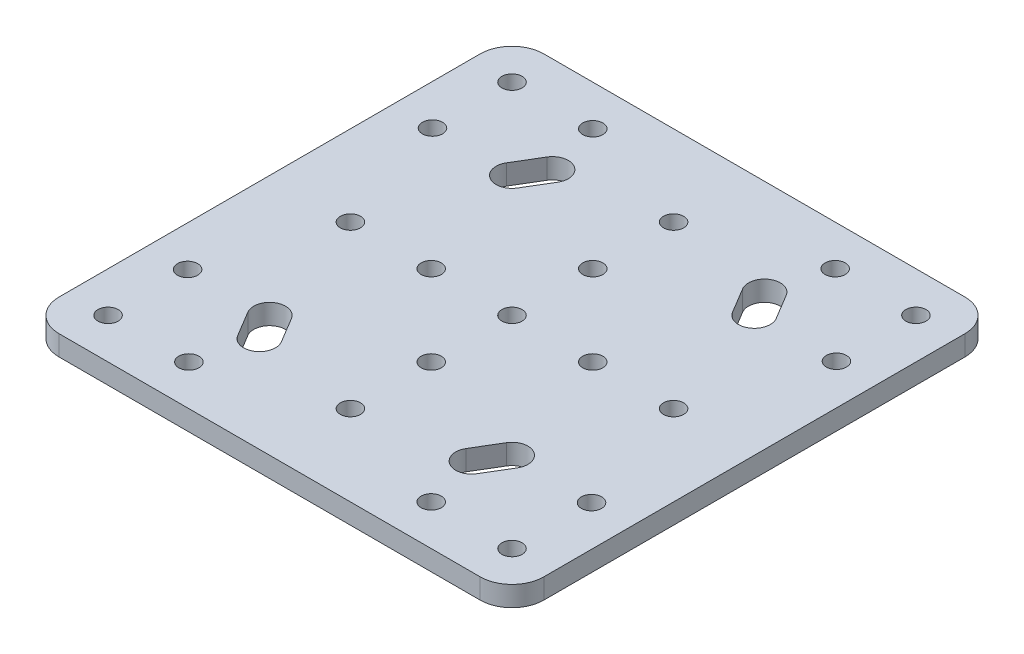
from build123d import *

# Parameters (mm, degrees)
SKETCH1_W           = 101.6
SKETCH1_H           = 114.3
BOSS_EXTRUDE2_DEPTH = 6.35
SKETCH4_W           = 152.4
SKETCH4_H           = 152.4
SKETCH4_W_2         = 101.6
SKETCH4_H_2         = 114.3
BOSS_EXTRUDE4_DEPTH = 6.35
FILLET1_R           = 10
SKETCH5_R           = 3.175
CUT_EXTRUDE1_DEPTH  = 6.35


with BuildPart() as part:
    # Sketch1 → Boss-Extrude2 (new body)
    with BuildSketch(Plane(origin=(0, 0, 0), x_dir=(1, 0, 0), z_dir=(0, 1, 0))):
        Rectangle(SKETCH1_W, SKETCH1_H)
        with BuildLine():
            ThreePointArc((33.812535371, 35.527521223), (40.672478777, 33.812535371), (42.387464629, 40.672478777))
            Line((42.387464629, 40.672478777), (37.624964629, 48.609978777))
            ThreePointArc((37.624964629, 48.609978777), (30.765021223, 50.324964629), (29.050035371, 43.465021223))
            Line((29.050035371, 43.465021223), (33.812535371, 35.527521223))
        make_face(mode=Mode.SUBTRACT)
        with BuildLine():
            ThreePointArc((-33.812535371, -35.527521223), (-40.672478777, -33.812535371), (-42.387464629, -40.672478777))
            Line((-42.387464629, -40.672478777), (-37.624964629, -48.609978777))
            ThreePointArc((-37.624964629, -48.609978777), (-30.765021223, -50.324964629), (-29.050035371, -43.465021223))
            Line((-29.050035371, -43.465021223), (-33.812535371, -35.527521223))
        make_face(mode=Mode.SUBTRACT)
        with BuildLine():
            ThreePointArc((-33.812535371, 35.527521223), (-40.672478777, 33.812535371), (-42.387464629, 40.672478777))
            Line((-42.387464629, 40.672478777), (-37.624964629, 48.609978777))
            ThreePointArc((-37.624964629, 48.609978777), (-30.765021223, 50.324964629), (-29.050035371, 43.465021223))
            Line((-29.050035371, 43.465021223), (-33.812535371, 35.527521223))
        make_face(mode=Mode.SUBTRACT)
        with BuildLine():
            Line((29.050035371, -43.465021223), (33.812535371, -35.527521223))
            ThreePointArc((33.812535371, -35.527521223), (40.672478777, -33.812535371), (42.387464629, -40.672478777))
            Line((42.387464629, -40.672478777), (37.624964629, -48.609978777))
            ThreePointArc((37.624964629, -48.609978777), (30.765021223, -50.324964629), (29.050035371, -43.465021223))
        make_face(mode=Mode.SUBTRACT)
    extrude(amount=BOSS_EXTRUDE2_DEPTH)

    # Sketch4 → Boss-Extrude4 (add)
    with BuildSketch(Plane(origin=(0, 6.35, 0), x_dir=(1, 0, 0), z_dir=(0, 1, 0))):
        Rectangle(SKETCH4_W, SKETCH4_H)
        Rectangle(SKETCH4_W_2, SKETCH4_H_2, mode=Mode.SUBTRACT)
    extrude(amount=-BOSS_EXTRUDE4_DEPTH)

    # Fillet1
    fillet1_edges = [part.edges().sort_by_distance(p)[0] for p in [
        (76.2, 3.175, -76.2),
        (76.2, 3.175, 76.2),
        (-76.2, 3.175, 76.2),
        (-76.2, 3.175, -76.2),
    ]]
    fillet(fillet1_edges, radius=FILLET1_R)

    # Sketch5 → Cut-Extrude1 (cut)
    with BuildSketch(Plane(origin=(0, 6.35, 0), x_dir=(1, 0, 0), z_dir=(0, 1, 0))):
        with Locations((-25.4, 0)):
            Circle(SKETCH5_R)
        with Locations((-50.8, 0)):
            Circle(SKETCH5_R)
        with Locations((50.8, 0)):
            Circle(SKETCH5_R)
        with Locations((0, -25.4)):
            Circle(SKETCH5_R)
        with Locations((-63.5, -38.5)):
            Circle(SKETCH5_R)
        with Locations((-63.5, -63.5)):
            Circle(SKETCH5_R)
        with Locations((-38.1, -63.5)):
            Circle(SKETCH5_R)
        with Locations((38.1, -63.5)):
            Circle(SKETCH5_R)
        with Locations((63.5, -38.5)):
            Circle(SKETCH5_R)
        with Locations((63.5, -63.5)):
            Circle(SKETCH5_R)
        with Locations((0, -50.8)):
            Circle(SKETCH5_R)
        with Locations((0, 25.4)):
            Circle(SKETCH5_R)
        with Locations((-63.5, 38.5)):
            Circle(SKETCH5_R)
        with Locations((-38.1, 63.5)):
            Circle(SKETCH5_R)
        Circle(SKETCH5_R)
        with Locations((25.4, 0)):
            Circle(SKETCH5_R)
        with Locations((63.5, 63.5)):
            Circle(SKETCH5_R)
        with Locations((63.5, 38.5)):
            Circle(SKETCH5_R)
        with Locations((38.1, 63.5)):
            Circle(SKETCH5_R)
        with Locations((0, 50.8)):
            Circle(SKETCH5_R)
        with Locations((-63.5, 63.5)):
            Circle(SKETCH5_R)
    extrude(amount=-CUT_EXTRUDE1_DEPTH, mode=Mode.SUBTRACT)


solid = part.part
